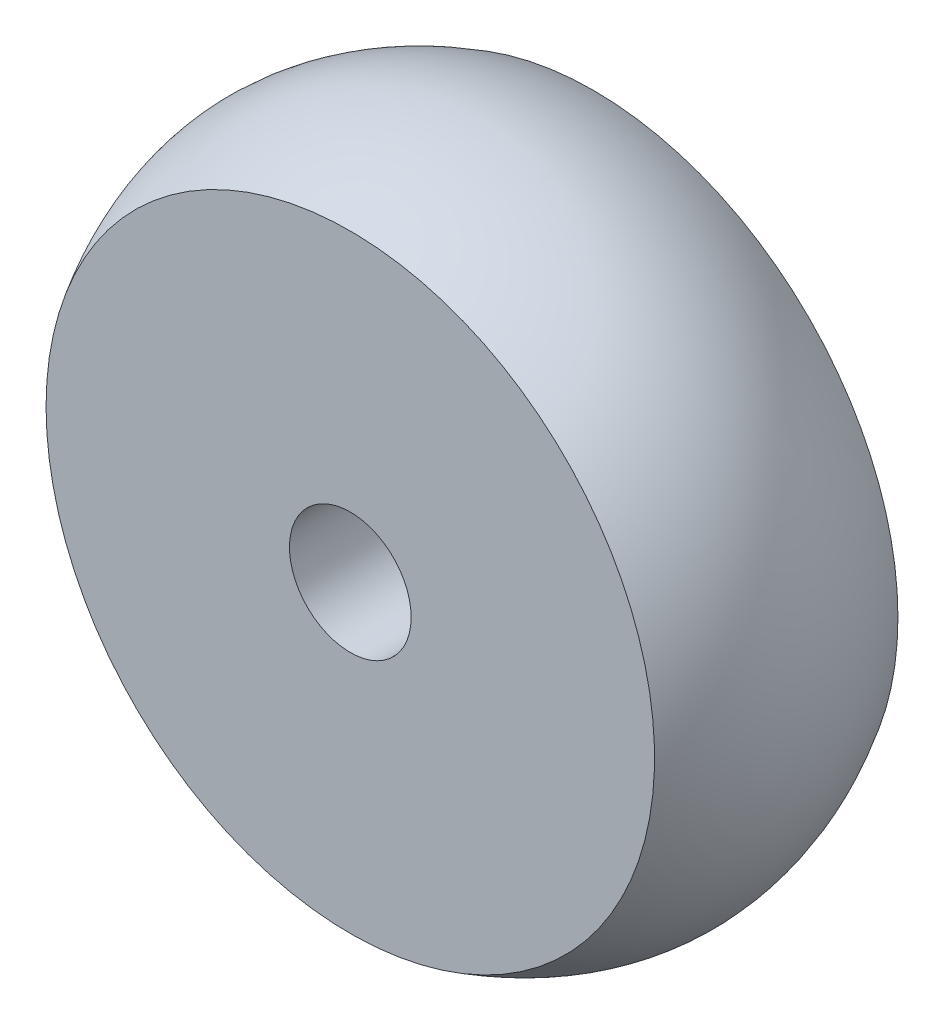
from build123d import *

# Parameters (mm, degrees)
SKETCH1_R           = 12.5
SKETCH1_R_2         = 2.5
BOSS_EXTRUDE1_DEPTH = 10


with BuildPart() as part:
    # Sketch1 → Boss-Extrude1 (new body)
    with BuildSketch(Plane.XY):
        Circle(SKETCH1_R)
        Circle(SKETCH1_R_2, mode=Mode.SUBTRACT)
    extrude(amount=BOSS_EXTRUDE1_DEPTH)

    # Sketch2 → Revolve1 (revolve)
    with BuildSketch(Plane(origin=(0, 0, 0), x_dir=(0, 0, -1), z_dir=(1, 0, 0))):
        with BuildLine():
            Line((-10, 12.5), (0, 12.5))
            add(Edge.make_bspline(
                [(-10, 12.5), (-5, 15.5), (0, 12.5)],
                knots=[0, 0, 0, 1, 1, 1], degree=2))
        make_face()
    revolve(axis=Axis((0, 0, 0), (0, 0, 1)))


solid = part.part
